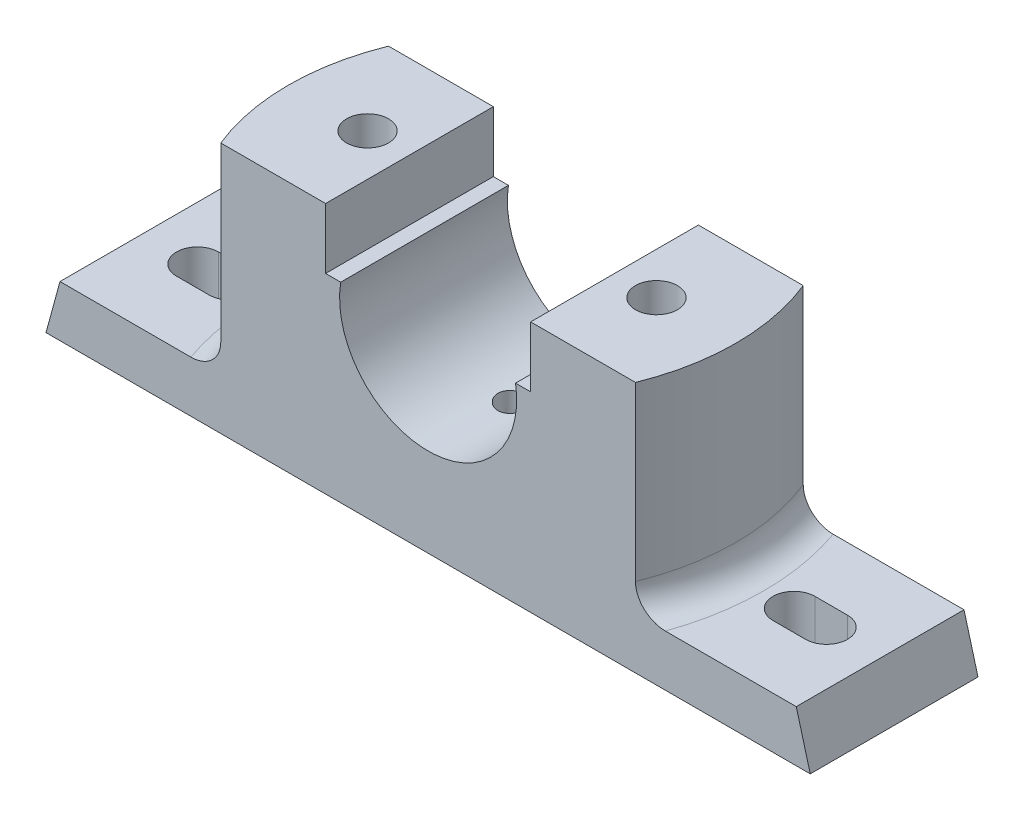
from build123d import *

# Parameters (mm, degrees)
BOSS_EXTRUDE1_DEPTH                 = 18
SKETCH2_W                           = 28
SKETCH2_H                           = 36
CUT_EXTRUDE1_DEPTH                  = 43
CUT_EXTRUDE2_DEPTH                  = 43
SKETCH4_W                           = 20
SKETCH4_H                           = 20
CUT_EXTRUDE3_DEPTH                  = 8
FILLET1_R                           = 6
CUT_EXTRUDE4_DEPTH                  = 12.0000001
F_6_0MM_DOWEL_HOLE3_D               = 6
F_6_0MM_DOWEL_HOLE3_DEPTH           = 6
F_6_0MM_DOWEL_HOLE3_TIP             = 1.802581857
F_6_0MM_DOWEL_HOLE3_ON_FACE_2_D     = 6
F_6_0MM_DOWEL_HOLE3_ON_FACE_2_DEPTH = 6
F_6_0MM_DOWEL_HOLE3_ON_FACE_2_TIP   = 1.802581857


with BuildPart() as part:
    # Sketch1 → Boss-Extrude1 (new body, symmetric)
    with BuildSketch(Plane.XY):
        with BuildLine():
            Line((-82, 0), (82, 0))
            Line((82, 0), (79, 11))
            Line((79, 11), (50, 11))
            Line((50, 11), (50, 54))
            Line((50, 54), (22, 54))
            Line((22, 54), (22, 41))
            Line((22, 41), (18.761663039, 41))
            ThreePointArc((18.761663039, 41), (0, 19), (-18.761663039, 41))
            Line((-18.761663039, 41), (-22, 41))
            Line((-22, 41), (-22, 54))
            Line((-22, 54), (-50, 54))
            Line((-50, 54), (-50, 11))
            Line((-50, 11), (-79, 11))
            Line((-79, 11), (-82, 0))
        make_face()
    boss_extrude1 = extrude(amount=BOSS_EXTRUDE1_DEPTH, both=True)

    # Sketch2 → Cut-Extrude1 (cut)
    with BuildSketch(Plane(origin=(0, 54, 0), x_dir=(1, 0, 0), z_dir=(0, 1, 0))):
        with Locations((-36, 0)):
            Rectangle(SKETCH2_W, SKETCH2_H)
    extrude(amount=-CUT_EXTRUDE1_DEPTH, mode=Mode.SUBTRACT)

    # Mirror1: Boss-Extrude1 across plane
    add(boss_extrude1.mirror(Plane(origin=(0, 0, 0), x_dir=(0, 0, 1), z_dir=(1, 0, 0))))

    # Sketch3 → Cut-Extrude2 (cut)
    with BuildSketch(Plane(origin=(0, 54, 0), x_dir=(1, 0, 0), z_dir=(0, 1, 0))):
        with BuildLine():
            Line((44.497190923, 18), (50, 18))
            Line((50, 18), (50, -18))
            Line((50, -18), (44.497190923, -18))
            ThreePointArc((44.497190923, -18), (48, 0), (44.497190923, 18))
        make_face()
    cut_extrude2 = extrude(amount=-CUT_EXTRUDE2_DEPTH, mode=Mode.SUBTRACT)

    # Mirror2: Cut-Extrude2 across plane
    add(cut_extrude2.mirror(Plane(origin=(0, 0, 0), x_dir=(0, 0, 1), z_dir=(1, 0, 0))), mode=Mode.SUBTRACT)

    # Sketch4 → Cut-Extrude3 (cut)
    with BuildSketch(Plane.XZ):
        with Locations((-31, 0)):
            Rectangle(SKETCH4_W, SKETCH4_H)
    cut_extrude3 = extrude(amount=-CUT_EXTRUDE3_DEPTH, mode=Mode.SUBTRACT)

    # Mirror3: Cut-Extrude3 across plane
    add(cut_extrude3.mirror(Plane(origin=(0, 0, 0), x_dir=(0, 0, 1), z_dir=(1, 0, 0))), mode=Mode.SUBTRACT)

    # Fillet1
    fillet1_edges = [part.edges().sort_by_distance(p)[0] for p in [
        (-48, 11, 0),
        (48, 11, 0),
    ]]
    fillet(fillet1_edges, radius=FILLET1_R)

    # Sketch10 → Ø6.0mm Dowel Hole2 (revolve, cut)
    with BuildSketch(Plane(origin=(-31, 54, 0), x_dir=(0, 0, 1), z_dir=(1, 0, 0))):
        Polygon((0, 0), (0, 56.703872786), (4.5, 54), (4.5, 0), align=None)
    f_6_0mm_dowel_hole2 = revolve(axis=Axis((-31, 60.35, 0), (0, -1, 0)), mode=Mode.SUBTRACT)

    # Mirror4: Ø6.0mm Dowel Hole2 across plane
    add(f_6_0mm_dowel_hole2.mirror(Plane(origin=(0, 0, 0), x_dir=(0, 0, 1), z_dir=(1, 0, 0))), mode=Mode.SUBTRACT)

    # Sketch18 → Cut-Extrude4 (cut, through all)
    with BuildSketch(Plane(origin=(0, 11, 0), x_dir=(1, 0, 0), z_dir=(0, 1, 0))):
        with BuildLine():
            Line((-67.5, 4.5), (-60.5, 4.5))
            ThreePointArc((-60.5, 4.5), (-56, 0), (-60.5, -4.5))
            Line((-60.5, -4.5), (-67.5, -4.5))
            ThreePointArc((-67.5, -4.5), (-72, 0), (-67.5, 4.5))
        make_face()
    cut_extrude4 = extrude(amount=-CUT_EXTRUDE4_DEPTH, mode=Mode.SUBTRACT)

    # Mirror5: Cut-Extrude4 across plane
    add(cut_extrude4.mirror(Plane(origin=(0, 0, 0), x_dir=(0, 0, 1), z_dir=(1, 0, 0))), mode=Mode.SUBTRACT)

    # Ø6.0mm Dowel Hole3
    with Locations(Plane(origin=(0, 19, 0), x_dir=(1, 0, 0), z_dir=(0, 1, 0))):
        with Locations((0, 0)):
            Hole(F_6_0MM_DOWEL_HOLE3_D / 2, depth=F_6_0MM_DOWEL_HOLE3_DEPTH)
            with Locations((0, 0, -(F_6_0MM_DOWEL_HOLE3_DEPTH + F_6_0MM_DOWEL_HOLE3_TIP / 2))):  # 118° drill point
                Cone(0, F_6_0MM_DOWEL_HOLE3_D / 2, F_6_0MM_DOWEL_HOLE3_TIP, mode=Mode.SUBTRACT)

    # Ø6.0mm Dowel Hole3 on face 2
    with Locations(Plane(origin=(-148.466540519, 0, -78.953744881), x_dir=(1, 0, 0), z_dir=(0, 1, 0))):
        with Locations((0, 0)):
            Hole(F_6_0MM_DOWEL_HOLE3_ON_FACE_2_D / 2, depth=F_6_0MM_DOWEL_HOLE3_ON_FACE_2_DEPTH)
            with Locations((0, 0, -(F_6_0MM_DOWEL_HOLE3_ON_FACE_2_DEPTH + F_6_0MM_DOWEL_HOLE3_ON_FACE_2_TIP / 2))):  # 118° drill point
                Cone(0, F_6_0MM_DOWEL_HOLE3_ON_FACE_2_D / 2, F_6_0MM_DOWEL_HOLE3_ON_FACE_2_TIP, mode=Mode.SUBTRACT)


solid = part.part
